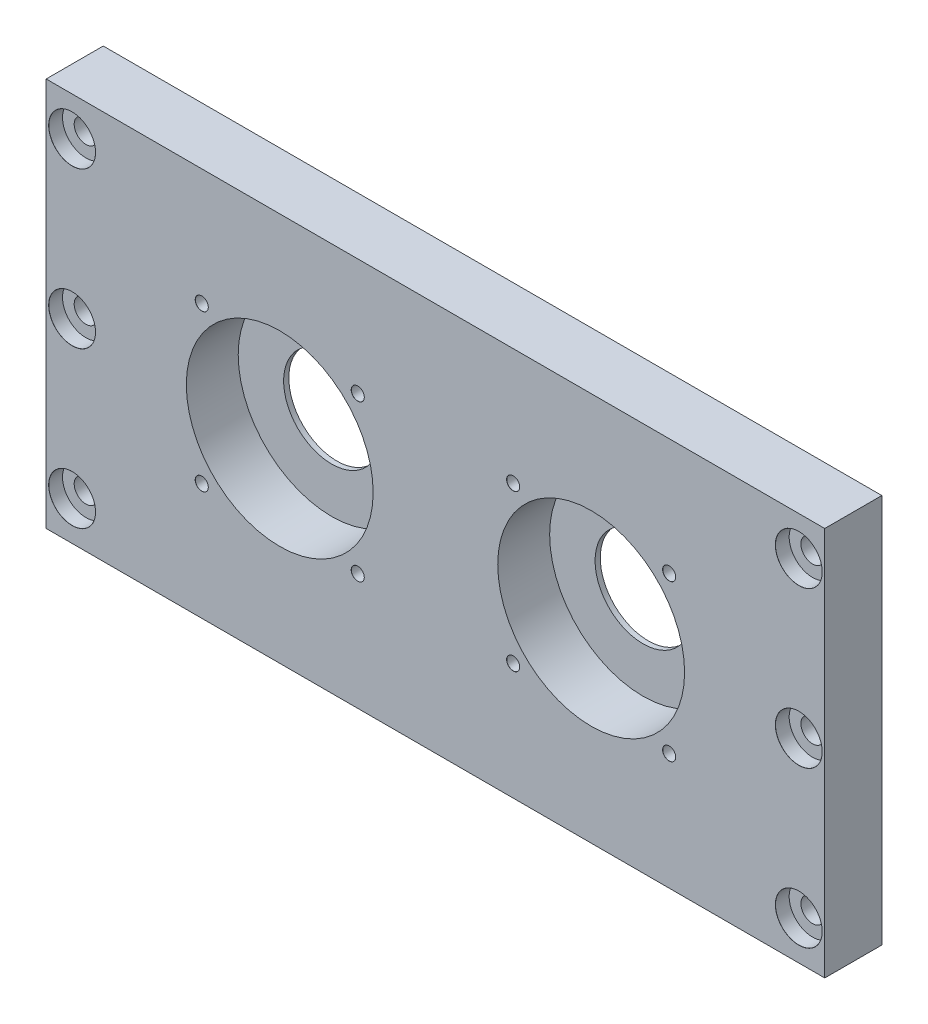
from build123d import *

# Parameters (mm, degrees)
SKETCH1_W                              = 300
SKETCH1_H                              = 150
BOSS_EXTRUDE1_DEPTH                    = 22
SKETCH2_R                              = 36
CUT_EXTRUDE1_DEPTH                     = 20
SKETCH3_R                              = 18.5
CUT_EXTRUDE2_DEPTH                     = 19
CBORE_FOR_M8_HEX_HEAD_BOLT1_AT_2_COUNT = 2
CBORE_FOR_M8_HEX_HEAD_BOLT1_AT_2_PITCH = 60
CBORE_FOR_M8_HEX_HEAD_BOLT1_AT_3_COUNT = 2
CBORE_FOR_M8_HEX_HEAD_BOLT1_AT_3_PITCH = 120
CIRPATTERN1_COUNT                      = 4


with BuildPart() as part:
    # Sketch1 → Boss-Extrude1 (new body)
    with BuildSketch(Plane.XY):
        Rectangle(SKETCH1_W, SKETCH1_H)
    extrude(amount=BOSS_EXTRUDE1_DEPTH)

    # Sketch2 → Cut-Extrude1 (cut)
    with BuildSketch(Plane.XY.offset(22)):
        with Locations((-60, 0)):
            Circle(SKETCH2_R)
    cut_extrude1 = extrude(amount=-CUT_EXTRUDE1_DEPTH, mode=Mode.SUBTRACT)

    # Sketch3 → Cut-Extrude2 (cut)
    with BuildSketch(Plane.XY.offset(2)):
        with Locations((-60, 0)):
            Circle(SKETCH3_R)
    cut_extrude2 = extrude(amount=-CUT_EXTRUDE2_DEPTH, mode=Mode.SUBTRACT)

    # Sketch6 → CBORE for M8 Hex Head Bolt1 (revolve, cut)
    with BuildSketch(Plane(origin=(-140, 60, 22), x_dir=(0, -1, 0), z_dir=(1, 0, 0))):
        Polygon((0, 0), (0, 27.5), (4.5, 24.796127214), (4.5, 5.3), (9.0055, 5.3), (9.0055, 0.025), (9.0305, 0), align=None)
    cbore_for_m8_hex_head_bolt1 = revolve(axis=Axis((-140, 60, 28.35), (0, 0, -1)), mode=Mode.SUBTRACT)

    # CBORE for M8 Hex Head Bolt1 at 2: CBORE for M8 Hex Head Bolt1 ×2
    with Locations(*[(0, -i * CBORE_FOR_M8_HEX_HEAD_BOLT1_AT_2_PITCH, 0) for i in range(1, CBORE_FOR_M8_HEX_HEAD_BOLT1_AT_2_COUNT)]):
        add(cbore_for_m8_hex_head_bolt1, mode=Mode.SUBTRACT)

    # CBORE for M8 Hex Head Bolt1 at 3: CBORE for M8 Hex Head Bolt1 ×2
    with Locations(*[(0, -i * CBORE_FOR_M8_HEX_HEAD_BOLT1_AT_3_PITCH, 0) for i in range(1, CBORE_FOR_M8_HEX_HEAD_BOLT1_AT_3_COUNT)]):
        add(cbore_for_m8_hex_head_bolt1, mode=Mode.SUBTRACT)

    # Mirror1: Cut-Extrude2, Cut-Extrude1, CBORE for M8 Hex Head Bolt1 across plane
    add(cut_extrude2.mirror(Plane(origin=(0, 0, 0), x_dir=(0, 0, 1), z_dir=(1, 0, 0))), mode=Mode.SUBTRACT)
    add(cut_extrude1.mirror(Plane(origin=(0, 0, 0), x_dir=(0, 0, 1), z_dir=(1, 0, 0))), mode=Mode.SUBTRACT)
    add(cbore_for_m8_hex_head_bolt1.mirror(Plane(origin=(0, 0, 0), x_dir=(0, 0, 1), z_dir=(1, 0, 0))), mode=Mode.SUBTRACT)

    # Mirror1 copy 1 sketch → Mirror1 copy 1 (revolve, cut)
    with BuildSketch(Plane(origin=(140, 0, 22), x_dir=(0, -1, 0), z_dir=(-1, 0, 0))):
        Polygon((0, 0), (0, -27.5), (4.5, -24.796127214), (4.5, -5.3), (9.0055, -5.3), (9.0055, -0.025), (9.0305, 0), align=None)
    revolve(axis=Axis((140, 0, 28.35), (0, 0, 1)), mode=Mode.SUBTRACT)

    # Mirror1 copy 2 sketch → Mirror1 copy 2 (revolve, cut)
    with BuildSketch(Plane(origin=(140, -60, 22), x_dir=(0, -1, 0), z_dir=(-1, 0, 0))):
        Polygon((0, 0), (0, -27.5), (4.5, -24.796127214), (4.5, -5.3), (9.0055, -5.3), (9.0055, -0.025), (9.0305, 0), align=None)
    revolve(axis=Axis((140, -60, 28.35), (0, 0, 1)), mode=Mode.SUBTRACT)

    # Sketch9 → Tap Drill for M6 Tap1 (revolve, cut)
    with BuildSketch(Plane(origin=(-29.9479618, 30.0520382, 22), x_dir=(0, -1, 0), z_dir=(1, 0, 0))):
        Polygon((0, 0), (0, 27.5), (2.5, 25.997848452), (2.5, 0.025), (2.525, 0), align=None)
    tap_drill_for_m6_tap1 = revolve(axis=Axis((-29.9479618, 30.0520382, 28.35), (0, 0, -1)), mode=Mode.SUBTRACT)

    # CirPattern1: Tap Drill for M6 Tap1 ×4 about axis
    cirpattern1_axis = Axis((-60, 0, 0), (0, 0, 1))
    for i in range(1, CIRPATTERN1_COUNT):
        add(tap_drill_for_m6_tap1.rotate(cirpattern1_axis, i * 360 / CIRPATTERN1_COUNT), mode=Mode.SUBTRACT)

    # Mirror2: Tap Drill for M6 Tap1 across plane
    add(tap_drill_for_m6_tap1.mirror(Plane(origin=(0, 0, 0), x_dir=(0, 0, 1), z_dir=(1, 0, 0))), mode=Mode.SUBTRACT)

    # Mirror2 copy 1 sketch → Mirror2 copy 1 (revolve, cut)
    with BuildSketch(Plane(origin=(90.0520382, 30.0520382, 22), x_dir=(-1, 0, 0), z_dir=(0, 1, 0))):
        Polygon((0, 0), (0, -27.5), (2.5, -25.997848452), (2.5, -0.025), (2.525, 0), align=None)
    revolve(axis=Axis((90.0520382, 30.0520382, 28.35), (0, 0, 1)), mode=Mode.SUBTRACT)

    # Mirror2 copy 2 sketch → Mirror2 copy 2 (revolve, cut)
    with BuildSketch(Plane(origin=(90.0520382, -30.0520382, 22), x_dir=(0, 1, 0), z_dir=(1, 0, 0))):
        Polygon((0, 0), (0, -27.5), (2.5, -25.997848452), (2.5, -0.025), (2.525, 0), align=None)
    revolve(axis=Axis((90.0520382, -30.0520382, 28.35), (0, 0, 1)), mode=Mode.SUBTRACT)

    # Mirror2 copy 3 sketch → Mirror2 copy 3 (revolve, cut)
    with BuildSketch(Plane(origin=(29.9479618, -30.0520382, 22), x_dir=(1, 0, 0), z_dir=(0, -1, 0))):
        Polygon((0, 0), (0, -27.5), (2.5, -25.997848452), (2.5, -0.025), (2.525, 0), align=None)
    revolve(axis=Axis((29.9479618, -30.0520382, 28.35), (0, 0, 1)), mode=Mode.SUBTRACT)


solid = part.part
